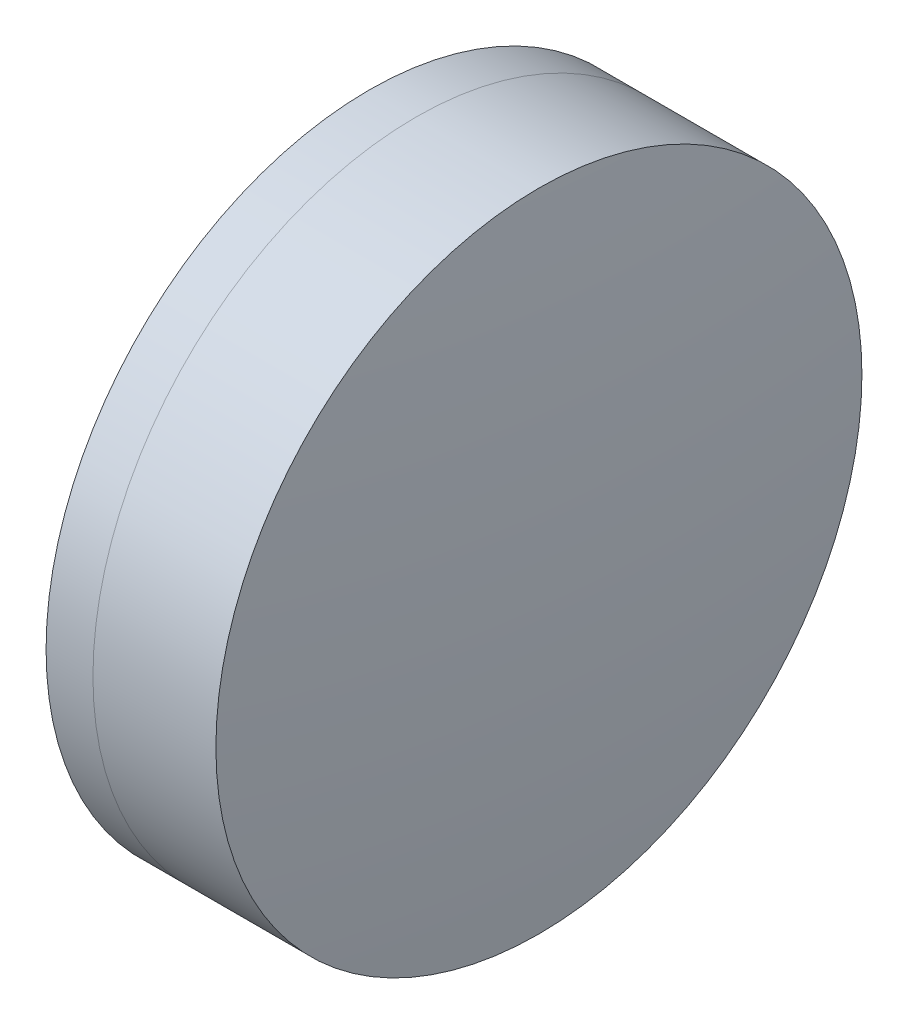
from build123d import *


with BuildPart() as part:
    # 草图1 one side → 旋转1 (revolve)
    with BuildSketch(Plane(origin=(0, 0, 0), x_dir=(1, 0, 0), z_dir=(0, 1, 0)), mode=Mode.PRIVATE) as revolve_1_sk:
        with BuildLine():
            ThreePointArc((256.584910904, 20), (252.897633822, 10.300619965), (251.644153201, 0))
            Line((251.644153201, 0), (265.644153201, 0))
            ThreePointArc((265.644153201, 0), (264.069962647, 10.463190543), (259.48676533, 20))
            Line((259.48676533, 20), (256.584910904, 20))
        make_face()
    revolve(revolve_1_sk.sketch.rotate(Axis((124.523309526, 0, 0), (1, 0, 0)), 180), axis=Axis((124.523309526, 0, 0), (1, 0, 0)))  # turned: the seam where the file's is


with BuildPart() as body_2:
    # 草图2 one side → 旋转3 (revolve)
    with BuildSketch(Plane(origin=(0, 0, 0), x_dir=(1, 0, 0), z_dir=(0, 1, 0)), mode=Mode.PRIVATE) as revolve_3_sk:
        with BuildLine():
            Line((267.098933825, 20), (259.48676533, 20))
            ThreePointArc((259.48676533, 20), (264.069962647, 10.463190543), (265.644153201, 0))
            Line((265.644153201, 0), (268.144153201, 0))
            ThreePointArc((268.144153201, 0), (267.882670181, 10.013646733), (267.098933825, 20))
        make_face()
    revolve(revolve_3_sk.sketch.rotate(Axis((-0.551919993, 0, 0), (1, 0, 0)), 180), axis=Axis((-0.551919993, 0, 0), (1, 0, 0)))  # turned: the seam where the file's is


solid = Compound([part.part, body_2.part])
